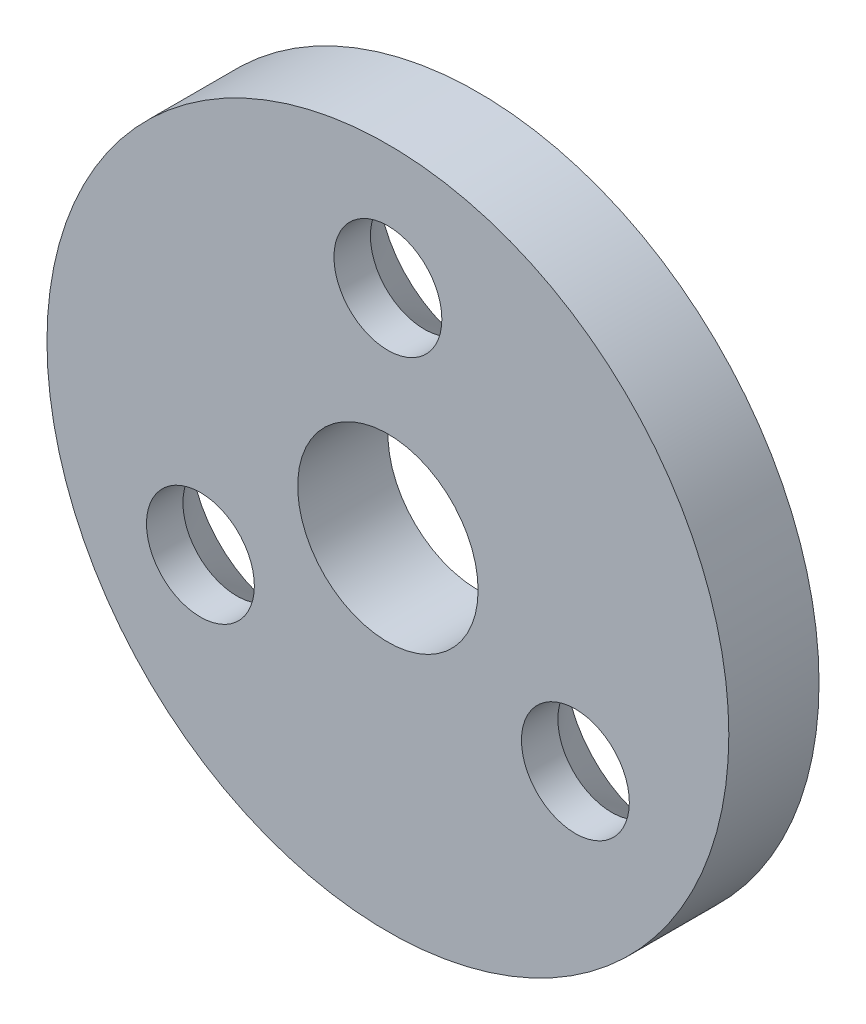
from build123d import *

# Parameters (mm, degrees)
SKETCH1_R                                      = 12
SKETCH1_R_2                                    = 3.175
BOSS_EXTRUDE1_DEPTH                            = 3.175
CSK_FOR_6_FLAT_HEAD_MACHINE_SCREW1_D           = 3.7973
CSK_FOR_6_FLAT_HEAD_MACHINE_SCREW1_DEPTH       = 10.973
CSK_FOR_6_FLAT_HEAD_MACHINE_SCREW1_CSINK_D     = 7.0866
CSK_FOR_6_FLAT_HEAD_MACHINE_SCREW1_CSINK_ANGLE = 82
CSK_FOR_6_FLAT_HEAD_MACHINE_SCREW1_TIP         = 1.140824014


with BuildPart() as part:
    # Sketch1 → Boss-Extrude1 (new body)
    with BuildSketch(Plane.XY):
        Circle(SKETCH1_R)
        Circle(SKETCH1_R_2, mode=Mode.SUBTRACT)
    extrude(amount=BOSS_EXTRUDE1_DEPTH)

    # CSK for _6 Flat Head Machine Screw1
    with Locations(Plane(origin=(0, 0, 0), x_dir=(-1, 0, 0), z_dir=(0, 0, -1))):
        with Locations((0, 7.62), (-6.599113577, -3.81), (6.599113577, -3.81)):
            CounterSinkHole(CSK_FOR_6_FLAT_HEAD_MACHINE_SCREW1_D / 2, CSK_FOR_6_FLAT_HEAD_MACHINE_SCREW1_CSINK_D / 2, depth=CSK_FOR_6_FLAT_HEAD_MACHINE_SCREW1_DEPTH, counter_sink_angle=CSK_FOR_6_FLAT_HEAD_MACHINE_SCREW1_CSINK_ANGLE)
            with Locations((0, 0, -(CSK_FOR_6_FLAT_HEAD_MACHINE_SCREW1_DEPTH + CSK_FOR_6_FLAT_HEAD_MACHINE_SCREW1_TIP / 2))):  # 118° drill point
                Cone(0, CSK_FOR_6_FLAT_HEAD_MACHINE_SCREW1_D / 2, CSK_FOR_6_FLAT_HEAD_MACHINE_SCREW1_TIP, mode=Mode.SUBTRACT)


solid = part.part
